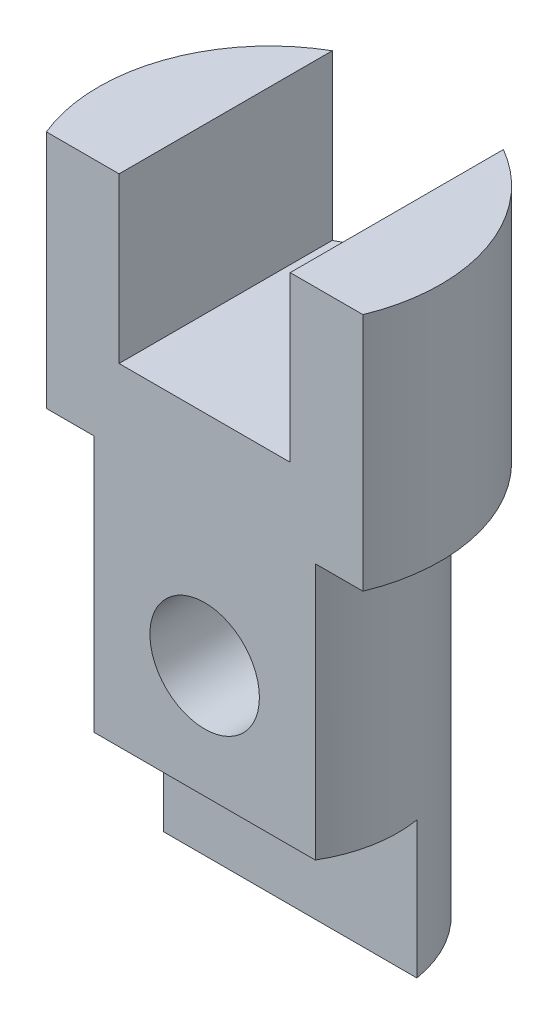
from build123d import *

# Parameters (mm, degrees)
BOSS_EXTRUDE1_DEPTH = 70
SKETCH2_W           = 50
SKETCH2_H           = 74.667138355
CUT_EXTRUDE1_DEPTH  = 48
BOSS_EXTRUDE2_DEPTH = 75
BOSS_EXTRUDE3_DEPTH = 40
SKETCH5_R           = 16
CUT_EXTRUDE2_DEPTH  = 70


with BuildPart() as part:
    # Sketch1 → Boss-Extrude1 (new body)
    with BuildSketch(Plane(origin=(0, 0, 0), x_dir=(1, 0, 0), z_dir=(0, 1, 0))):
        with BuildLine():
            Line((-46.249324319, -19), (46.249324319, -19))
            ThreePointArc((46.249324319, -19), (0, 50), (-46.249324319, -19))
        make_face()
    extrude(amount=BOSS_EXTRUDE1_DEPTH)

    # Sketch2 → Cut-Extrude1 (cut)
    with BuildSketch(Plane(origin=(0, 70, 0), x_dir=(1, 0, 0), z_dir=(0, 1, 0))):
        with Locations((0, 18.333569178)):
            Rectangle(SKETCH2_W, SKETCH2_H)
    extrude(amount=-CUT_EXTRUDE1_DEPTH, mode=Mode.SUBTRACT)

    # Sketch3 → Boss-Extrude2 (add)
    with BuildSketch(Plane.XZ):
        with BuildLine():
            Line((32.330326321, 19), (-32.330326321, 19))
            ThreePointArc((-32.330326321, 19), (0, -37.5), (32.330326321, 19))
        make_face()
    extrude(amount=BOSS_EXTRUDE2_DEPTH)

    # Sketch4 → Boss-Extrude3 (add)
    with BuildSketch(Plane.XZ.offset(75)):
        with BuildLine():
            Line((-37.016888038, -6), (37.016888038, -6))
            ThreePointArc((37.016888038, -6), (0, -37.5), (-37.016888038, -6))
        make_face()
    extrude(amount=BOSS_EXTRUDE3_DEPTH)

    # Sketch5 → Cut-Extrude2 (cut, through all)
    with BuildSketch(Plane.XY.offset(19)):
        with Locations((0, -42)):
            Circle(SKETCH5_R)
    extrude(amount=-CUT_EXTRUDE2_DEPTH, mode=Mode.SUBTRACT)


solid = part.part
